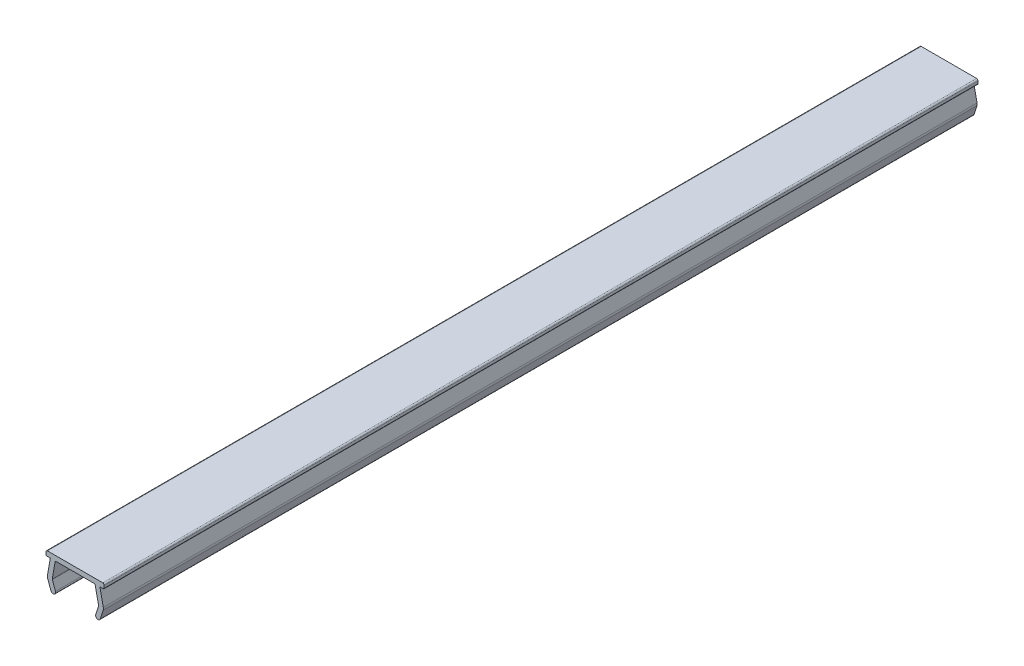
from build123d import *

# Parameters (mm, degrees)
EXTRUDE_1_DEPTH = 180


with BuildPart() as part:
    # 草图1 → 拉伸1 (new body)
    with BuildSketch(Plane.XY):
        with BuildLine():
            Line((11.786098163, 93.447548514), (11.185365906, 91.59914157))
            ThreePointArc((11.185365906, 91.59914157), (10.555305835, 91.278167571), (10.234331837, 91.908227642))
            Line((10.234331837, 91.908227642), (10.817155535, 93.701531326))
            ThreePointArc((10.817155535, 93.701531326), (10.82905345, 93.765700722), (10.823937692, 93.830763005))
            Line((10.823937692, 93.830763005), (10.12292529, 97.129945359))
            ThreePointArc((10.12292529, 97.129945359), (10.053162473, 97.243801851), (9.92729275, 97.28837723))
            Line((9.92729275, 97.28837723), (2.076289972, 97.28837723))
            ThreePointArc((2.076289972, 97.28837723), (1.94773245, 97.241586118), (1.879328421, 97.123106865))
            Line((1.879328421, 97.123106865), (1.291080466, 93.786986931))
            ThreePointArc((1.291080466, 93.786986931), (1.28823373, 93.721785951), (1.302359249, 93.658069851))
            Line((1.302359249, 93.658069851), (1.947284603, 91.886152004))
            ThreePointArc((1.947284603, 91.886152004), (1.648448364, 91.245295622), (1.007591982, 91.544131861))
            Line((1.007591982, 91.544131861), (0.339755623, 93.378997177))
            ThreePointArc((0.339755623, 93.378997177), (0.283253546, 93.633861578), (0.294640491, 93.894665498))
            Line((0.294640491, 93.894665498), (0.893043434, 97.28837723))
            Line((0.893043434, 97.28837723), (0.200002689, 97.28837723))
            ThreePointArc((0.200002689, 97.28837723), (0.058581333, 97.346955874), (2.689e-06, 97.48837723))
            Line((2.689e-06, 97.48837723), (2.689e-06, 97.98837723))
            ThreePointArc((2.689e-06, 97.98837723), (0.087870655, 98.200509264), (0.300002689, 98.28837723))
            Line((0.300002689, 98.28837723), (11.700002689, 98.28837723))
            ThreePointArc((11.700002689, 98.28837723), (11.912134724, 98.200509264), (12.000002689, 97.98837723))
            Line((12.000002689, 97.98837723), (12.000002689, 97.48837723))
            ThreePointArc((12.000002689, 97.48837723), (11.941424046, 97.346955874), (11.800002689, 97.28837723))
            Line((11.800002689, 97.28837723), (11.106961944, 97.28837723))
            Line((11.106961944, 97.28837723), (11.813226794, 93.96447523))
            ThreePointArc((11.813226794, 93.96447523), (11.833689825, 93.704226096), (11.786098163, 93.447548514))
        make_face()
    extrude(amount=EXTRUDE_1_DEPTH)


solid = part.part
